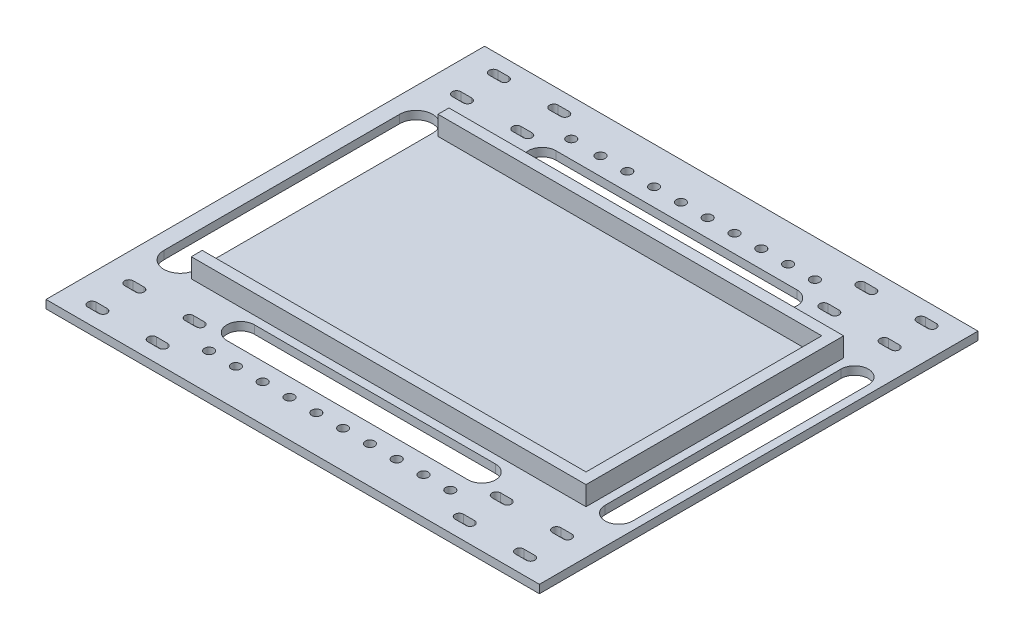
from build123d import *

# Parameters (mm, degrees)
SKETCH1_W            = 180
SKETCH1_H            = 160
BOSS_EXTRUDE1_DEPTH  = 3
BOSS_EXTRUDE2_DEPTH  = 10
M3_CLEARANCE_HOLE1_D = 3.4


with BuildPart() as part:
    # Sketch1 → Boss-Extrude1 (new body)
    with BuildSketch(Plane(origin=(0, 0, 0), x_dir=(1, 0, 0), z_dir=(0, 1, 0))):
        Rectangle(SKETCH1_W, SKETCH1_H)
        with BuildLine():
            Line((-80, -58.195), (-76, -58.195))
            ThreePointArc((-76, -58.195), (-74.445, -59.75), (-76, -61.305))
            Line((-76, -61.305), (-80, -61.305))
            ThreePointArc((-80, -61.305), (-81.555, -59.75), (-80, -58.195))
        make_face(mode=Mode.SUBTRACT)
        with BuildLine():
            Line((-58, -58.195), (-54, -58.195))
            ThreePointArc((-54, -58.195), (-52.445, -59.75), (-54, -61.305))
            Line((-54, -61.305), (-58, -61.305))
            ThreePointArc((-58, -61.305), (-59.555, -59.75), (-58, -58.195))
        make_face(mode=Mode.SUBTRACT)
        with BuildLine():
            Line((-80, -71.695), (-76, -71.695))
            ThreePointArc((-76, -71.695), (-74.445, -73.25), (-76, -74.805))
            Line((-76, -74.805), (-80, -74.805))
            ThreePointArc((-80, -74.805), (-81.555, -73.25), (-80, -71.695))
        make_face(mode=Mode.SUBTRACT)
        with BuildLine():
            Line((-58, -71.695), (-54, -71.695))
            ThreePointArc((-54, -71.695), (-52.445, -73.25), (-54, -74.805))
            Line((-54, -74.805), (-58, -74.805))
            ThreePointArc((-58, -74.805), (-59.555, -73.25), (-58, -71.695))
        make_face(mode=Mode.SUBTRACT)
        with BuildLine():
            Line((-80, 71.695), (-76, 71.695))
            ThreePointArc((-76, 71.695), (-74.445, 73.25), (-76, 74.805))
            Line((-76, 74.805), (-80, 74.805))
            ThreePointArc((-80, 74.805), (-81.555, 73.25), (-80, 71.695))
        make_face(mode=Mode.SUBTRACT)
        with BuildLine():
            Line((-58, 71.695), (-54, 71.695))
            ThreePointArc((-54, 71.695), (-52.445, 73.25), (-54, 74.805))
            Line((-54, 74.805), (-58, 74.805))
            ThreePointArc((-58, 74.805), (-59.555, 73.25), (-58, 71.695))
        make_face(mode=Mode.SUBTRACT)
        with BuildLine():
            Line((-58, 58.195), (-54, 58.195))
            ThreePointArc((-54, 58.195), (-52.445, 59.75), (-54, 61.305))
            Line((-54, 61.305), (-58, 61.305))
            ThreePointArc((-58, 61.305), (-59.555, 59.75), (-58, 58.195))
        make_face(mode=Mode.SUBTRACT)
        with BuildLine():
            Line((-80, 58.195), (-76, 58.195))
            ThreePointArc((-76, 58.195), (-74.445, 59.75), (-76, 61.305))
            Line((-76, 61.305), (-80, 61.305))
            ThreePointArc((-80, 61.305), (-81.555, 59.75), (-80, 58.195))
        make_face(mode=Mode.SUBTRACT)
        with BuildLine():
            Line((80, -71.695), (76, -71.695))
            ThreePointArc((76, -71.695), (74.445, -73.25), (76, -74.805))
            Line((76, -74.805), (80, -74.805))
            ThreePointArc((80, -74.805), (81.555, -73.25), (80, -71.695))
        make_face(mode=Mode.SUBTRACT)
        with BuildLine():
            Line((80, -58.195), (76, -58.195))
            ThreePointArc((76, -58.195), (74.445, -59.75), (76, -61.305))
            Line((76, -61.305), (80, -61.305))
            ThreePointArc((80, -61.305), (81.555, -59.75), (80, -58.195))
        make_face(mode=Mode.SUBTRACT)
        with BuildLine():
            Line((58, -58.195), (54, -58.195))
            ThreePointArc((54, -58.195), (52.445, -59.75), (54, -61.305))
            Line((54, -61.305), (58, -61.305))
            ThreePointArc((58, -61.305), (59.555, -59.75), (58, -58.195))
        make_face(mode=Mode.SUBTRACT)
        with BuildLine():
            Line((58, -71.695), (54, -71.695))
            ThreePointArc((54, -71.695), (52.445, -73.25), (54, -74.805))
            Line((54, -74.805), (58, -74.805))
            ThreePointArc((58, -74.805), (59.555, -73.25), (58, -71.695))
        make_face(mode=Mode.SUBTRACT)
        with BuildLine():
            Line((80, 58.195), (76, 58.195))
            ThreePointArc((76, 58.195), (74.445, 59.75), (76, 61.305))
            Line((76, 61.305), (80, 61.305))
            ThreePointArc((80, 61.305), (81.555, 59.75), (80, 58.195))
        make_face(mode=Mode.SUBTRACT)
        with BuildLine():
            Line((58, 58.195), (54, 58.195))
            ThreePointArc((54, 58.195), (52.445, 59.75), (54, 61.305))
            Line((54, 61.305), (58, 61.305))
            ThreePointArc((58, 61.305), (59.555, 59.75), (58, 58.195))
        make_face(mode=Mode.SUBTRACT)
        with BuildLine():
            Line((58, 71.695), (54, 71.695))
            ThreePointArc((54, 71.695), (52.445, 73.25), (54, 74.805))
            Line((54, 74.805), (58, 74.805))
            ThreePointArc((58, 74.805), (59.555, 73.25), (58, 71.695))
        make_face(mode=Mode.SUBTRACT)
        with BuildLine():
            Line((80, 71.695), (76, 71.695))
            ThreePointArc((76, 71.695), (74.445, 73.25), (76, 74.805))
            Line((76, 74.805), (80, 74.805))
            ThreePointArc((80, 74.805), (81.555, 73.25), (80, 71.695))
        make_face(mode=Mode.SUBTRACT)
        with BuildLine():
            Line((-84, -43), (-84, 43))
            ThreePointArc((-84, 43), (-78, 49), (-72, 43))
            Line((-72, 43), (-72, -43))
            ThreePointArc((-72, -43), (-78, -49), (-84, -43))
        make_face(mode=Mode.SUBTRACT)
        with BuildLine():
            Line((77, -43), (77, 43))
            ThreePointArc((77, 43), (82, 48), (87, 43))
            Line((87, 43), (87, -43))
            ThreePointArc((87, -43), (82, -48), (77, -43))
        make_face(mode=Mode.SUBTRACT)
        with BuildLine():
            Line((-44, 60), (44, 60))
            ThreePointArc((44, 60), (49, 55), (44, 50))
            Line((44, 50), (-44, 50))
            ThreePointArc((-44, 50), (-49, 55), (-44, 60))
        make_face(mode=Mode.SUBTRACT)
        with BuildLine():
            Line((-44, -60), (44, -60))
            ThreePointArc((44, -60), (49, -55), (44, -50))
            Line((44, -50), (-44, -50))
            ThreePointArc((-44, -50), (-49, -55), (-44, -60))
        make_face(mode=Mode.SUBTRACT)
    extrude(amount=BOSS_EXTRUDE1_DEPTH)

    # Sketch1_3 → Boss-Extrude2 (add)
    with BuildSketch(Plane(origin=(0, 0, 0), x_dir=(1, 0, 0), z_dir=(0, 1, 0))):
        Polygon((-70, 47), (-70, 43), (70, 43), (70, -43), (-70, -43), (-70, -47), (74, -47), (74, 47), align=None)
    extrude(amount=BOSS_EXTRUDE2_DEPTH)

    # M3 Clearance Hole1 (through all)
    with Locations(Plane(origin=(0, 3, 0), x_dir=(1, 0, 0), z_dir=(0, 1, 0))):
        with Locations((-44, -66.5), (-34.222222222, -66.5), (-24.444444444, -66.5), (-14.666666667, -66.5), (-4.888888889, -66.5), (4.888888889, -66.5), (14.666666667, -66.5), (24.444444444, -66.5), (34.222222222, -66.5), (44, -66.5), (44, 66.5), (34.222222222, 66.5), (24.444444444, 66.5), (14.666666667, 66.5), (4.888888889, 66.5), (-4.888888889, 66.5), (-14.666666667, 66.5), (-24.444444444, 66.5), (-34.222222222, 66.5), (-44.881291433, 66.5)):
            Hole(M3_CLEARANCE_HOLE1_D / 2)


solid = part.part
